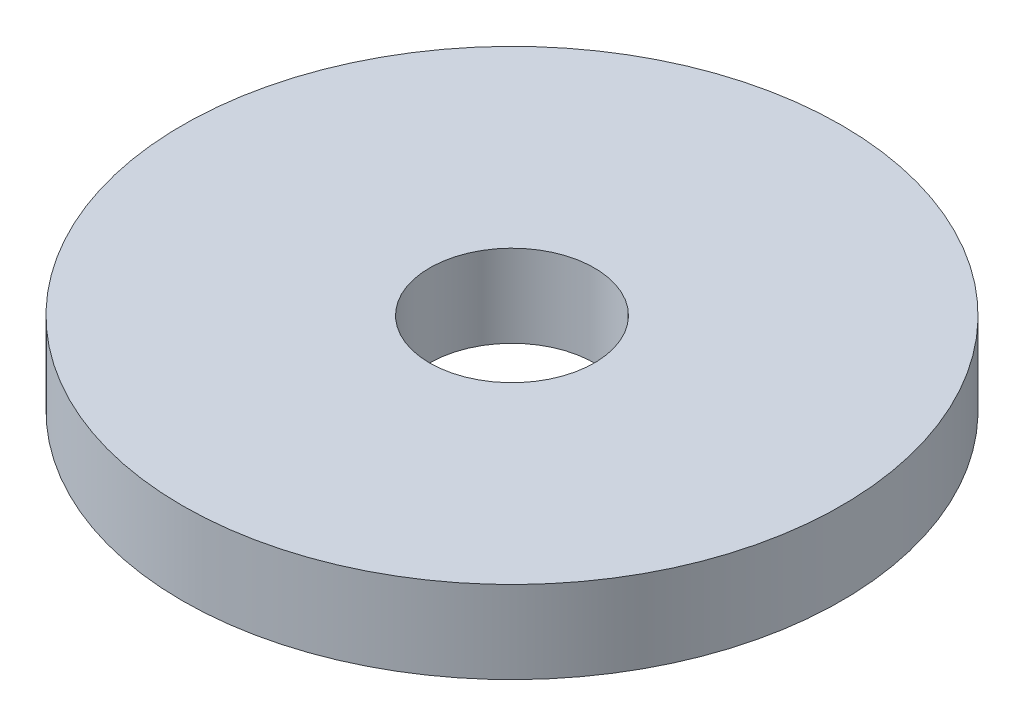
from build123d import *

# Parameters (mm, degrees)
SKETCH1_R           = 20
SKETCH1_R_2         = 5
BOSS_EXTRUDE1_DEPTH = 5


with BuildPart() as part:
    # Sketch1 → Boss-Extrude1 (new body)
    with BuildSketch(Plane(origin=(0, 0, 0), x_dir=(1, 0, 0), z_dir=(0, 1, 0))):
        Circle(SKETCH1_R)
        Circle(SKETCH1_R_2, mode=Mode.SUBTRACT)
    extrude(amount=BOSS_EXTRUDE1_DEPTH)


solid = part.part
